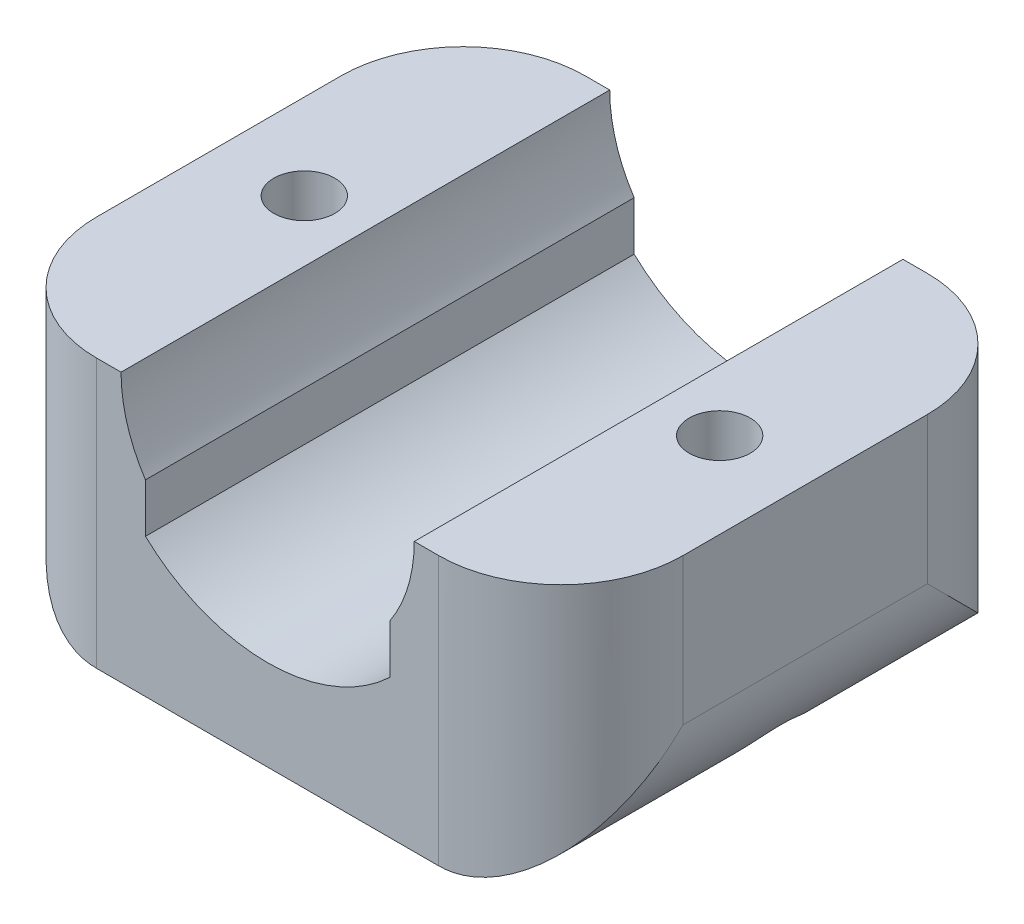
from build123d import *

# Parameters (mm, degrees)
BOSS_EXTRUDE1_DEPTH     = 10
SKETCH2_W               = 10
SKETCH2_H               = 5.318834459
CUT_EXTRUDE1_DEPTH      = 11
CUT_EXTRUDE1_DEPTH_BACK = 11
SKETCH3_R               = 1.25
CUT_EXTRUDE2_DEPTH      = 17
FILLET1_R               = 5
CUT_EXTRUDE3_DEPTH      = 11
CUT_EXTRUDE3_DEPTH_BACK = 11
SKETCH5_R               = 2.5
CUT_EXTRUDE4_DEPTH      = 6


with BuildPart() as part:
    # Sketch1 → Boss-Extrude1 (new body, symmetric)
    with BuildSketch(Plane.XY):
        with BuildLine():
            Line((12, 0), (6, 0))
            ThreePointArc((6, 0), (0, -6), (-6, 0))
            Line((-6, 0), (-12, 0))
            Line((-12, 0), (-12, -11))
            Line((-12, -11), (12, -11))
            Line((12, -11), (12, 0))
        make_face()
    extrude(amount=BOSS_EXTRUDE1_DEPTH, both=True)

    # Sketch2 → Cut-Extrude1 (cut, two sides)
    with BuildSketch(Plane.XY) as cut_extrude1_sk:
        with BuildLine():
            Line((5, -5.318834459), (-5, -5.318834459))
            ThreePointArc((-5, -5.318834459), (0, -7.3), (5, -5.318834459))
        make_face()
        with Locations((0, -2.65941723)):
            Rectangle(SKETCH2_W, SKETCH2_H)
    extrude(amount=CUT_EXTRUDE1_DEPTH, mode=Mode.SUBTRACT)
    extrude(cut_extrude1_sk.sketch, amount=-CUT_EXTRUDE1_DEPTH_BACK, mode=Mode.SUBTRACT)

    # Sketch3 → Cut-Extrude2 (cut)
    with BuildSketch(Plane(origin=(0, 0, 0), x_dir=(1, 0, 0), z_dir=(0, 1, 0))):
        with Locations((-8.5, 0)):
            Circle(SKETCH3_R)
        with Locations((8.5, 0)):
            Circle(SKETCH3_R)
    extrude(amount=-CUT_EXTRUDE2_DEPTH, mode=Mode.SUBTRACT)

    # Fillet1
    fillet1_edges = [part.edges().sort_by_distance(p)[0] for p in [
        (12, -5.5, 10),
        (-12, -5.5, 10),
        (-12, -5.5, -10),
        (12, -5.5, -10),
    ]]
    fillet(fillet1_edges, radius=FILLET1_R)

    # Sketch4 → Cut-Extrude3 (cut, two sides)
    with BuildSketch(Plane.XY) as cut_extrude3_sk:
        with BuildLine():
            ThreePointArc((7, -11), (10.535533906, -9.535533906), (12, -6))
            Line((12, -6), (12, -11))
            Line((12, -11), (7, -11))
        make_face()
        with BuildLine():
            ThreePointArc((-12, -6), (-10.535533906, -9.535533906), (-7, -11))
            Line((-7, -11), (-12, -11))
            Line((-12, -11), (-12, -6))
        make_face()
    extrude(amount=CUT_EXTRUDE3_DEPTH, mode=Mode.SUBTRACT)
    extrude(cut_extrude3_sk.sketch, amount=-CUT_EXTRUDE3_DEPTH_BACK, mode=Mode.SUBTRACT)

    # Sketch5 → Cut-Extrude4 (cut)
    with BuildSketch(Plane.XZ.offset(11)):
        with Locations((-8.5, 0)):
            Circle(SKETCH5_R)
        with Locations((8.5, 0)):
            Circle(SKETCH5_R)
    extrude(amount=-CUT_EXTRUDE4_DEPTH, mode=Mode.SUBTRACT)


solid = part.part
